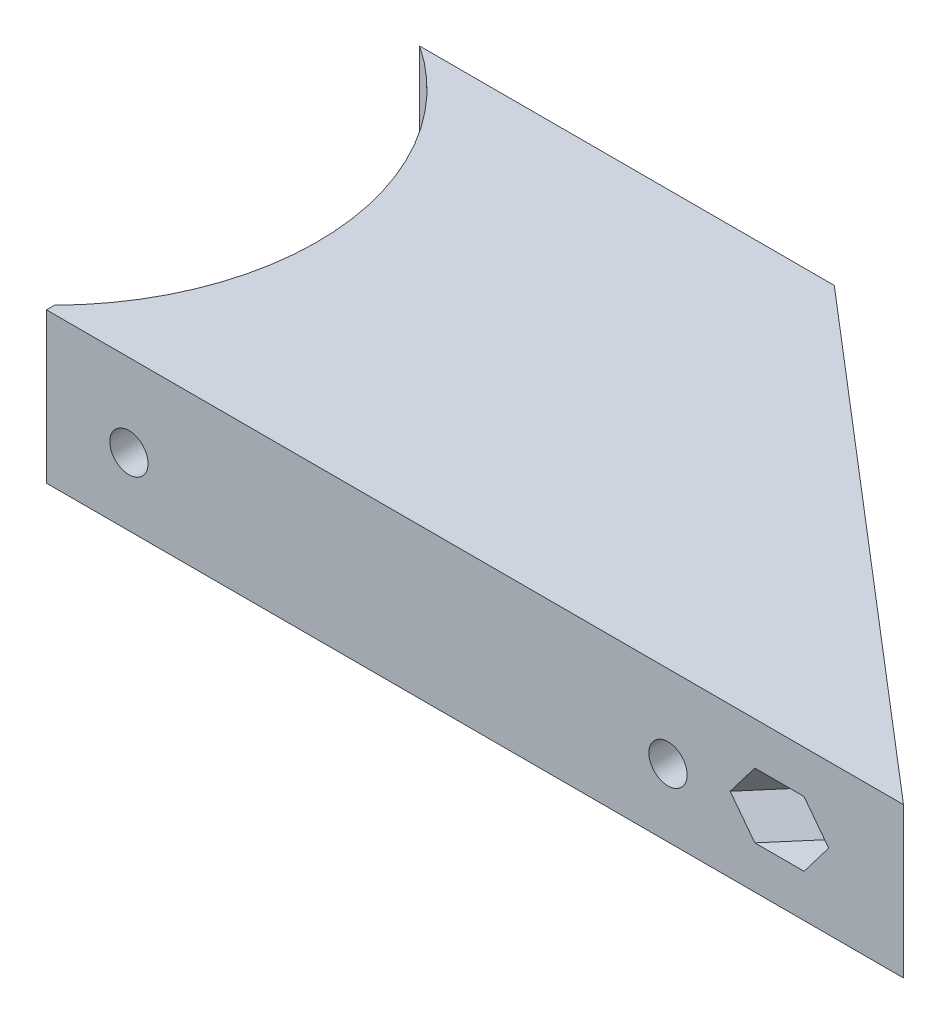
from build123d import *

# Parameters (mm, degrees)
SALIENTE_EXTRUIR1_DEPTH = 12.75
CORTAR_EXTRUIR1_REACH   = 31.62
CROQUIS2_R              = 1.625
CROQUIS3_R              = 22.5
CORTAR_EXTRUIR2_DEPTH   = 13.75
SALIENTE_EXTRUIR2_DEPTH = 3
SALIENTE_EXTRUIR3_DEPTH = 9.75
CROQUIS6_R              = 1.625
CORTAR_EXTRUIR3_DEPTH   = 10
CORTAR_EXTRUIR4_START   = -2
CORTAR_EXTRUIR4_DEPTH   = 10
CORTAR_EXTRUIR5_START   = -2
CORTAR_EXTRUIR5_DEPTH   = 10
CORTAR_EXTRUIR6_DEPTH   = 2
CORTAR_EXTRUIR7_REACH   = 37.25
CROQUIS10_R             = 1.625
CORTAR_EXTRUIR8_DEPTH   = 2


with BuildPart() as part:
    # Croquis1 → Saliente-Extruir1 (new body)
    with BuildSketch(Plane(origin=(0, 0, 0), x_dir=(1, 0, 0), z_dir=(0, 1, 0))):
        Polygon((0, 0), (72.78319995, 0), (38.224450787, 29.62043043), (35.621353918, 26.5833452), (60.803074847, 5), (0, 5), align=None)
    extrude(amount=SALIENTE_EXTRUIR1_DEPTH)

    # Croquis2 → Cortar-Extruir1 (cut, up to next)
    with BuildSketch(Plane.XY, mode=Mode.PRIVATE) as cortar_extruir1_sk1:
        with Locations((52.78319995, 5.75)):
            Circle(CROQUIS2_R)
    cortar_extruir1_tool1 = extrude(cortar_extruir1_sk1.sketch, amount=-CORTAR_EXTRUIR1_REACH, mode=Mode.PRIVATE) & part.part
    add(cortar_extruir1_tool1.solids().sort_by_distance((52.7832, 5.75, 0))[0], mode=Mode.SUBTRACT)
    # Croquis2 → Cortar-Extruir1 (cut, up to next)
    with BuildSketch(Plane.XY, mode=Mode.PRIVATE) as cortar_extruir1_sk2:
        with Locations((6.99999995, 5.75)):
            Circle(CROQUIS2_R)
    cortar_extruir1_tool2 = extrude(cortar_extruir1_sk2.sketch, amount=-CORTAR_EXTRUIR1_REACH, mode=Mode.PRIVATE) & part.part
    add(cortar_extruir1_tool2.solids().sort_by_distance((7, 5.75, 0))[0], mode=Mode.SUBTRACT)

    # Croquis3 → Cortar-Extruir2 (cut, through all)
    with BuildSketch(Plane(origin=(0, 12.75, 0), x_dir=(1, 0, 0), z_dir=(0, 1, 0))):
        with Locations((-16, 16.5)):
            Circle(CROQUIS3_R)
    extrude(amount=-CORTAR_EXTRUIR2_DEPTH, mode=Mode.SUBTRACT)

    # Croquis4 → Saliente-Extruir2 (add)
    with BuildSketch(Plane(origin=(0, 12.75, 0), x_dir=(1, 0, 0), z_dir=(0, 1, 0))):
        with BuildLine():
            Line((38.224450787, 29.62043043), (31.656319269, 35.25))
            Line((31.656319269, 35.25), (-3.562657036, 35.25))
            ThreePointArc((-3.562657036, 35.25), (5.936291456, 21.504909307), (3.339079606, 5))
            Line((3.339079606, 5), (60.803074847, 5))
            Line((60.803074847, 5), (35.621353918, 26.5833452))
            Line((35.621353918, 26.5833452), (38.224450787, 29.62043043))
        make_face()
    extrude(amount=-SALIENTE_EXTRUIR2_DEPTH)

    # Croquis5 → Saliente-Extruir3 (add)
    with BuildSketch(Plane.XZ.offset(-9.75)):
        with BuildLine():
            Line((-3.562657036, -35.25), (31.656319269, -35.25))
            Line((31.656319269, -35.25), (38.224450787, -29.62043043))
            Line((38.224450787, -29.62043043), (35.621353918, -26.5833452))
            Line((35.621353918, -26.5833452), (30.17667434, -31.25))
            Line((30.17667434, -31.25), (0.990806338, -31.25))
            ThreePointArc((0.990806338, -31.25), (-1.15062315, -33.404023402), (-3.562657036, -35.25))
        make_face()
    extrude(amount=SALIENTE_EXTRUIR3_DEPTH)

    # Croquis6 → Cortar-Extruir3 (cut)
    with BuildSketch(Plane(origin=(30.824200619, 0, -35.963211942), x_dir=(-0.759271307, 0, -0.650774217), z_dir=(0.650774217, 0, -0.759271307))):
        with Locations((-47.262195378, 6.375)):
            Circle(CROQUIS6_R)
        with Locations((-16.095943758, 6.375)):
            Circle(CROQUIS6_R)
    extrude(amount=-CORTAR_EXTRUIR3_DEPTH, mode=Mode.SUBTRACT)

    # Croquis7 → Cortar-Extruir4 (cut)
    with BuildSketch(Plane(origin=(28.22110375, 0, -32.926126712), x_dir=(0.759271307, 0, 0.650774217), z_dir=(-0.650774217, 0, 0.759271307)).offset(CORTAR_EXTRUIR4_START)):
        Polygon((48.849908618, 3.625), (50.437621859, 6.375), (48.849908618, 9.125), (45.674482138, 9.125), (44.086768898, 6.375), (45.674482138, 3.625), align=None)
    extrude(amount=CORTAR_EXTRUIR4_DEPTH, mode=Mode.SUBTRACT)

    # Croquis8 → Cortar-Extruir5 (cut)
    with BuildSketch(Plane(origin=(28.22110375, 0, -32.926126712), x_dir=(0.759271307, 0, 0.650774217), z_dir=(-0.650774217, 0, 0.759271307)).offset(CORTAR_EXTRUIR5_START)):
        Polygon((17.683656999, 3.625), (19.271370239, 6.375), (17.683656999, 9.125), (14.508230518, 9.125), (12.920517278, 6.375), (14.508230518, 3.625), align=None)
    extrude(amount=CORTAR_EXTRUIR5_DEPTH, mode=Mode.SUBTRACT)

    # Croquis9 → Cortar-Extruir6 (cut)
    with BuildSketch(Plane(origin=(0, 0, -5), x_dir=(-1, 0, 0), z_dir=(0, 0, -1))):
        Polygon((-5.41228671, 3), (-3.824573469, 5.75), (-5.41228671, 8.5), (-8.58771319, 8.5), (-10.175426431, 5.75), (-8.58771319, 3), align=None)
        Polygon((-51.19548671, 3), (-49.607773469, 5.75), (-51.19548671, 8.5), (-54.37091319, 8.5), (-55.958626431, 5.75), (-54.37091319, 3), align=None)
    extrude(amount=-CORTAR_EXTRUIR6_DEPTH, mode=Mode.SUBTRACT)

    # Croquis10 → Cortar-Extruir7 (cut, up to next)
    with BuildSketch(Plane(origin=(0, 0, -35.25), x_dir=(-1, 0, 0), z_dir=(0, 0, -1)), mode=Mode.PRIVATE) as cortar_extruir7_sk1:
        with Locations((-21.656319269, 6.375)):
            Circle(CROQUIS10_R)
    cortar_extruir7_tool1 = extrude(cortar_extruir7_sk1.sketch, amount=-CORTAR_EXTRUIR7_REACH, mode=Mode.PRIVATE) & part.part
    add(cortar_extruir7_tool1.solids().sort_by_distance((21.656319, 6.375, -35.25))[0], mode=Mode.SUBTRACT)

    # Croquis11 → Cortar-Extruir8 (cut)
    with BuildSketch(Plane.XY.offset(-31.25)):
        Polygon((23.24403251, 3.625), (24.83174575, 6.375), (23.24403251, 9.125), (20.068606029, 9.125), (18.480892789, 6.375), (20.068606029, 3.625), align=None)
    extrude(amount=-CORTAR_EXTRUIR8_DEPTH, mode=Mode.SUBTRACT)


solid = part.part
